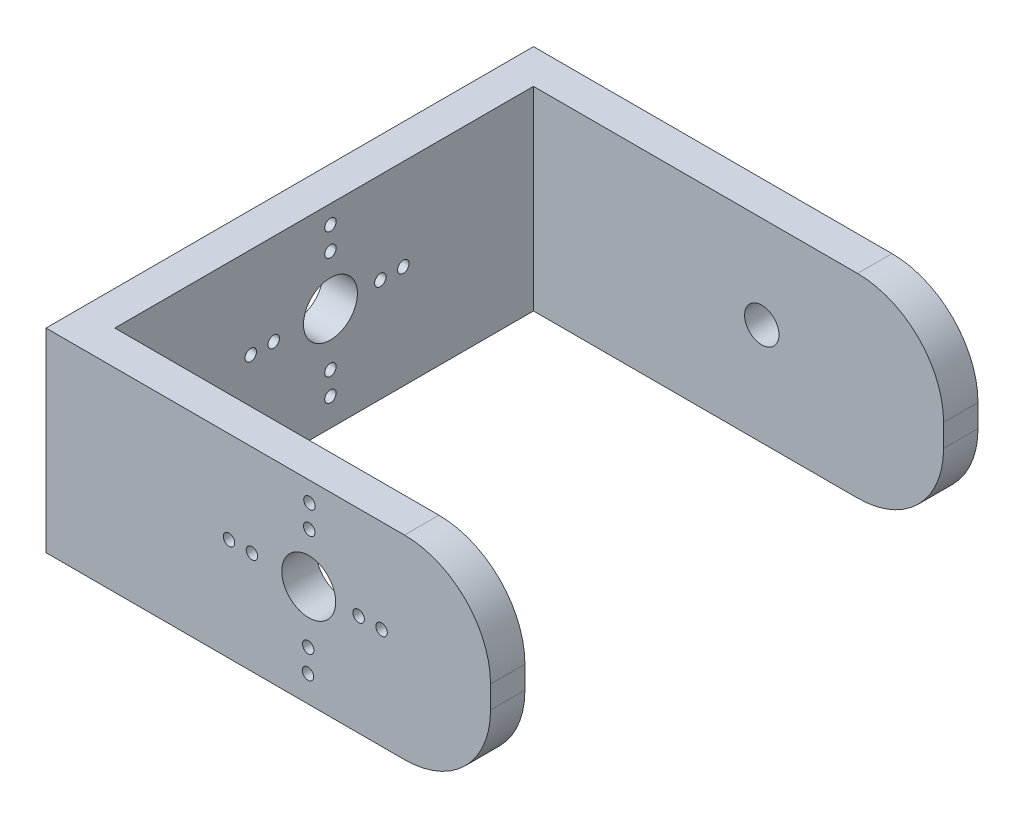
from build123d import *

# Parameters (mm, degrees)
SKETCH1_W           = 68.327661803
SKETCH1_H           = 52.686389824
BOSS_EXTRUDE1_DEPTH = 3
CUT_EXTRUDE1_DEPTH  = 100
SKETCH4_W           = 3
SKETCH4_H           = 16.961263462
BOSS_EXTRUDE2_DEPTH = 4
SKETCH5_W           = 3
SKETCH5_H           = 16.961263462
BOSS_EXTRUDE3_DEPTH = 39.5
SKETCH6_W           = 3
SKETCH6_H           = 16.961263462
BOSS_EXTRUDE4_DEPTH = 35.75429
FILLET1_R           = 7.5
FILLET2_R           = 7.5
FILLET3_R           = 7.5
FILLET4_R           = 7.5
SKETCH9_R           = 0.5
CUT_EXTRUDE5_DEPTH  = 14
SKETCH7_R           = 0.5
CUT_EXTRUDE6_DEPTH  = 14
SKETCH10_R          = 2.35
CUT_EXTRUDE7_DEPTH  = 10
SKETCH11_R          = 2.35
CUT_EXTRUDE8_DEPTH  = 10
SKETCH12_R          = 1.5
CUT_EXTRUDE9_DEPTH  = 10


with BuildPart() as part:
    # Sketch1 → Boss-Extrude1 (new body)
    with BuildSketch(Plane.XY):
        with Locations((-34.163830901, 26.343194912)):
            Rectangle(SKETCH1_W, SKETCH1_H)
    extrude(amount=BOSS_EXTRUDE1_DEPTH)

    # Sketch2 → Cut-Extrude1 (cut)
    with BuildSketch(Plane(origin=(0, 0, 0), x_dir=(-1, 0, 0), z_dir=(0, 0, -1))):
        Polygon((34.754290268, 32.233658713), (0, 32.233658713), (0, 52.686389824), (34.754290268, 52.686389824), (68.327661803, 52.686389824), (68.327661803, 0), (34.754290268, 0), (0, 0), (0, 15.272395251), (34.754290268, 15.272395251), align=None)
    extrude(amount=-CUT_EXTRUDE1_DEPTH, mode=Mode.SUBTRACT)

    # Sketch4 → Boss-Extrude2 (add)
    with BuildSketch(Plane.ZY.offset(34.754290268)):
        with Locations((1.5, 23.753026982)):
            Rectangle(SKETCH4_W, SKETCH4_H)
    extrude(amount=BOSS_EXTRUDE2_DEPTH)

    # Sketch5 → Boss-Extrude3 (add)
    with BuildSketch(Plane(origin=(0, 0, 0), x_dir=(-1, 0, 0), z_dir=(0, 0, -1))):
        with Locations((37.254290268, 23.753026982)):
            Rectangle(SKETCH5_W, SKETCH5_H)
    extrude(amount=BOSS_EXTRUDE3_DEPTH)

    # Sketch6 → Boss-Extrude4 (add)
    with BuildSketch(Plane(origin=(-35.754290268, 0, 0), x_dir=(0, 0, -1), z_dir=(1, 0, 0))):
        with Locations((38, 23.753026982)):
            Rectangle(SKETCH6_W, SKETCH6_H)
    extrude(amount=BOSS_EXTRUDE4_DEPTH)

    # Fillet1
    fillet1_edges = [part.edges().sort_by_distance(p)[0] for p in [
        (0, 15.272395251, 1.5),
    ]]
    fillet(fillet1_edges, radius=FILLET1_R)

    # Fillet2
    fillet2_edges = [part.edges().sort_by_distance(p)[0] for p in [
        (0, 32.233658713, 1.5),
    ]]
    fillet(fillet2_edges, radius=FILLET2_R)

    # Fillet3
    fillet3_edges = [part.edges().sort_by_distance(p)[0] for p in [
        (-2.68e-07, 32.233658713, -38),
    ]]
    fillet(fillet3_edges, radius=FILLET3_R)

    # Fillet4
    fillet4_edges = [part.edges().sort_by_distance(p)[0] for p in [
        (-2.68e-07, 15.272395251, -38),
    ]]
    fillet(fillet4_edges, radius=FILLET4_R)

    # Sketch9 → Cut-Extrude5 (cut)
    with BuildSketch(Plane.ZY.offset(38.754290268)):
        with Locations((-13.849226824, 24.283657668)):
            Circle(SKETCH9_R)
        with Locations((-11.849226824, 24.283657668)):
            Circle(SKETCH9_R)
        with Locations((-18.799226824, 19.683657668)):
            Circle(SKETCH9_R)
        with Locations((-18.799226824, 17.683657668)):
            Circle(SKETCH9_R)
        with Locations((-23.149226824, 24.283657668)):
            Circle(SKETCH9_R)
        with Locations((-25.149226824, 24.283657668)):
            Circle(SKETCH9_R)
        with Locations((-18.799226824, 30.633657668)):
            Circle(SKETCH9_R)
        with Locations((-18.799226824, 28.633657668)):
            Circle(SKETCH9_R)
    extrude(amount=-CUT_EXTRUDE5_DEPTH, mode=Mode.SUBTRACT)

    # Sketch7 → Cut-Extrude6 (cut)
    with BuildSketch(Plane(origin=(0, 0, 0), x_dir=(-1, 0, 0), z_dir=(0, 0, -1))):
        with Locations((15.785473329, 30.515840692)):
            Circle(SKETCH7_R)
        with Locations((15.805568543, 28.515941649)):
            Circle(SKETCH7_R)
        with Locations((20.799025765, 24.215896885)):
            Circle(SKETCH7_R)
        with Locations((22.798924808, 24.235992099)):
            Circle(SKETCH7_R)
        with Locations((11.499495215, 24.12245414)):
            Circle(SKETCH7_R)
        with Locations((9.499596172, 24.102358926)):
            Circle(SKETCH7_R)
        with Locations((15.895494626, 19.566393431)):
            Circle(SKETCH7_R)
        with Locations((15.91558984, 17.566494388)):
            Circle(SKETCH7_R)
    extrude(amount=-CUT_EXTRUDE6_DEPTH, mode=Mode.SUBTRACT)

    # Sketch10 → Cut-Extrude7 (cut)
    with BuildSketch(Plane.ZY.offset(38.754290268)):
        with Locations((-18.799226824, 24.283657668)):
            Circle(SKETCH10_R)
    extrude(amount=-CUT_EXTRUDE7_DEPTH, mode=Mode.SUBTRACT)

    # Sketch11 → Cut-Extrude8 (cut)
    with BuildSketch(Plane(origin=(0, 0, 0), x_dir=(-1, 0, 0), z_dir=(0, 0, -1))):
        with Locations((15.849275634, 24.16616123)):
            Circle(SKETCH11_R)
    extrude(amount=-CUT_EXTRUDE8_DEPTH, mode=Mode.SUBTRACT)

    # Sketch12 → Cut-Extrude9 (cut)
    with BuildSketch(Plane.XY.offset(-36.5)):
        with Locations((-15.849275634, 24.16616123)):
            Circle(SKETCH12_R)
    extrude(amount=-CUT_EXTRUDE9_DEPTH, mode=Mode.SUBTRACT)


solid = part.part
